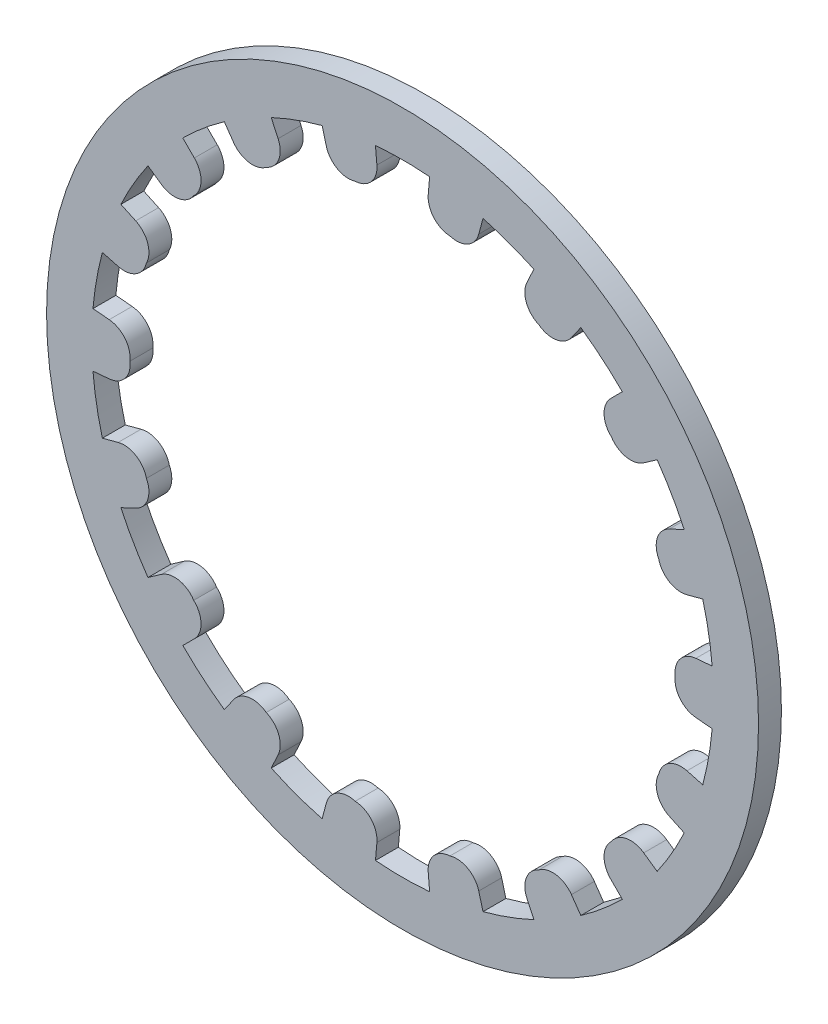
from build123d import *

# Parameters (mm, degrees)
BOSS_EXTRUDE1_DEPTH      = 0.254
BOSS_EXTRUDE1_DEPTH_BACK = 0.254
SKETCH1_R                = 7.8994


with BuildPart() as part:
    # Sketch1 → Boss-Extrude1 (new, two sides: drawn at the far end of the back side and taken through both)
    with BuildSketch(Plane.XY.offset(-BOSS_EXTRUDE1_DEPTH_BACK)):
        Circle(SKETCH1_R)
        with BuildLine():
            Line((-6.869858258, 0.601034718), (-6.508618542, 0.569430338))
            ThreePointArc((-6.508618542, 0.569430338), (-6.15764295, 0.382488604), (-6.048860848, 0))
            ThreePointArc((-6.048860848, 0), (-6.15764295, -0.382488604), (-6.508618542, -0.569430338))
            Line((-6.508618542, -0.569430338), (-6.869858258, -0.601034718))
            ThreePointArc((-6.869858258, -0.601034718), (-6.791332746, -1.197495198), (-6.661121091, -1.784842017))
            Line((-6.661121091, -1.784842017), (-6.310857462, -1.69098916))
            ThreePointArc((-6.310857462, -1.69098916), (-5.917110449, -1.746616205), (-5.684069903, -2.068832254))
            ThreePointArc((-5.684069903, -2.068832254), (-5.655472834, -2.465459643), (-5.92134417, -2.761168133))
            Line((-5.92134417, -2.761168133), (-6.24998913, -2.914417795))
            ThreePointArc((-6.24998913, -2.914417795), (-5.972197787, -3.44805), (-5.648954413, -3.955440463))
            Line((-5.648954413, -3.955440463), (-5.351913832, -3.747450409))
            ThreePointArc((-5.351913832, -3.747450409), (-4.9628871, -3.665053323), (-4.63369624, -3.888132806))
            ThreePointArc((-4.63369624, -3.888132806), (-4.471169229, -4.251059863), (-4.619868301, -4.619868301))
            Line((-4.619868301, -4.619868301), (-4.876279074, -4.876279074))
            ThreePointArc((-4.876279074, -4.876279074), (-4.432727635, -5.282719084), (-3.955440463, -5.648954413))
            Line((-3.955440463, -5.648954413), (-3.747450409, -5.351913832))
            ThreePointArc((-3.747450409, -5.351913832), (-3.410066323, -5.14143092), (-3.024430424, -5.238467158))
            ThreePointArc((-3.024430424, -5.238467158), (-2.747576627, -5.523919524), (-2.761168133, -5.92134417))
            Line((-2.761168133, -5.92134417), (-2.914417795, -6.24998913))
            ThreePointArc((-2.914417795, -6.24998913), (-2.35860511, -6.480214282), (-1.784842017, -6.661121091))
            Line((-1.784842017, -6.661121091), (-1.69098916, -6.310857462))
            ThreePointArc((-1.69098916, -6.310857462), (-1.44594122, -5.997676068), (-1.050373663, -5.95696506))
            ThreePointArc((-1.050373663, -5.95696506), (-0.692585734, -6.130512966), (-0.569430338, -6.508618542))
            Line((-0.569430338, -6.508618542), (-0.601034718, -6.869858258))
            ThreePointArc((-0.601034718, -6.869858258), (0, -6.8961), (0.601034718, -6.869858258))
            Line((0.601034718, -6.869858258), (0.569430338, -6.508618542))
            ThreePointArc((0.569430338, -6.508618542), (0.692585734, -6.130512966), (1.050373663, -5.95696506))
            ThreePointArc((1.050373663, -5.95696506), (1.44594122, -5.997676068), (1.69098916, -6.310857462))
            Line((1.69098916, -6.310857462), (1.784842017, -6.661121091))
            ThreePointArc((1.784842017, -6.661121091), (2.35860511, -6.480214282), (2.914417795, -6.24998913))
            Line((2.914417795, -6.24998913), (2.761168133, -5.92134417))
            ThreePointArc((2.761168133, -5.92134417), (2.747576627, -5.523919524), (3.024430424, -5.238467158))
            ThreePointArc((3.024430424, -5.238467158), (3.410066323, -5.14143092), (3.747450409, -5.351913832))
            Line((3.747450409, -5.351913832), (3.955440463, -5.648954413))
            ThreePointArc((3.955440463, -5.648954413), (4.432727635, -5.282719084), (4.876279074, -4.876279074))
            Line((4.876279074, -4.876279074), (4.619868301, -4.619868301))
            ThreePointArc((4.619868301, -4.619868301), (4.471169229, -4.251059863), (4.63369624, -3.888132806))
            ThreePointArc((4.63369624, -3.888132806), (4.9628871, -3.665053323), (5.351913832, -3.747450409))
            Line((5.351913832, -3.747450409), (5.648954413, -3.955440463))
            ThreePointArc((5.648954413, -3.955440463), (5.972197787, -3.44805), (6.24998913, -2.914417795))
            Line((6.24998913, -2.914417795), (5.92134417, -2.761168133))
            ThreePointArc((5.92134417, -2.761168133), (5.655472834, -2.465459643), (5.684069903, -2.068832254))
            ThreePointArc((5.684069903, -2.068832254), (5.917110449, -1.746616205), (6.310857462, -1.69098916))
            Line((6.310857462, -1.69098916), (6.661121091, -1.784842017))
            ThreePointArc((6.661121091, -1.784842017), (6.791332746, -1.197495198), (6.869858258, -0.601034718))
            Line((6.869858258, -0.601034718), (6.508618542, -0.569430338))
            ThreePointArc((6.508618542, -0.569430338), (6.15764295, -0.382488604), (6.048860848, 0))
            ThreePointArc((6.048860848, 0), (6.15764295, 0.382488604), (6.508618542, 0.569430338))
            Line((6.508618542, 0.569430338), (6.869858258, 0.601034718))
            ThreePointArc((6.869858258, 0.601034718), (6.791332746, 1.197495198), (6.661121091, 1.784842017))
            Line((6.661121091, 1.784842017), (6.310857462, 1.69098916))
            ThreePointArc((6.310857462, 1.69098916), (5.917110449, 1.746616205), (5.684069903, 2.068832254))
            ThreePointArc((5.684069903, 2.068832254), (5.655472834, 2.465459643), (5.92134417, 2.761168133))
            Line((5.92134417, 2.761168133), (6.24998913, 2.914417795))
            ThreePointArc((6.24998913, 2.914417795), (5.972197787, 3.44805), (5.648954413, 3.955440463))
            Line((5.648954413, 3.955440463), (5.351913832, 3.747450409))
            ThreePointArc((5.351913832, 3.747450409), (4.9628871, 3.665053323), (4.63369624, 3.888132806))
            ThreePointArc((4.63369624, 3.888132806), (4.471169229, 4.251059863), (4.619868301, 4.619868301))
            Line((4.619868301, 4.619868301), (4.876279074, 4.876279074))
            ThreePointArc((4.876279074, 4.876279074), (4.432727635, 5.282719084), (3.955440463, 5.648954413))
            Line((3.955440463, 5.648954413), (3.747450409, 5.351913832))
            ThreePointArc((3.747450409, 5.351913832), (3.410066323, 5.14143092), (3.024430424, 5.238467158))
            ThreePointArc((3.024430424, 5.238467158), (2.747576627, 5.523919524), (2.761168133, 5.92134417))
            Line((2.761168133, 5.92134417), (2.914417795, 6.24998913))
            ThreePointArc((2.914417795, 6.24998913), (2.35860511, 6.480214282), (1.784842017, 6.661121091))
            Line((1.784842017, 6.661121091), (1.69098916, 6.310857462))
            ThreePointArc((1.69098916, 6.310857462), (1.44594122, 5.997676068), (1.050373663, 5.95696506))
            ThreePointArc((1.050373663, 5.95696506), (0.692585734, 6.130512966), (0.569430338, 6.508618542))
            Line((0.569430338, 6.508618542), (0.601034718, 6.869858258))
            ThreePointArc((0.601034718, 6.869858258), (0, 6.8961), (-0.601034718, 6.869858258))
            Line((-0.601034718, 6.869858258), (-0.569430338, 6.508618542))
            ThreePointArc((-0.569430338, 6.508618542), (-0.692585734, 6.130512966), (-1.050373663, 5.95696506))
            ThreePointArc((-1.050373663, 5.95696506), (-1.44594122, 5.997676068), (-1.69098916, 6.310857462))
            Line((-1.69098916, 6.310857462), (-1.784842017, 6.661121091))
            ThreePointArc((-1.784842017, 6.661121091), (-2.35860511, 6.480214282), (-2.914417795, 6.24998913))
            Line((-2.914417795, 6.24998913), (-2.761168133, 5.92134417))
            ThreePointArc((-2.761168133, 5.92134417), (-2.747576627, 5.523919524), (-3.024430424, 5.238467158))
            ThreePointArc((-3.024430424, 5.238467158), (-3.410066323, 5.14143092), (-3.747450409, 5.351913832))
            Line((-3.747450409, 5.351913832), (-3.955440463, 5.648954413))
            ThreePointArc((-3.955440463, 5.648954413), (-4.432727635, 5.282719084), (-4.876279074, 4.876279074))
            Line((-4.876279074, 4.876279074), (-4.619868301, 4.619868301))
            ThreePointArc((-4.619868301, 4.619868301), (-4.471169229, 4.251059863), (-4.63369624, 3.888132806))
            ThreePointArc((-4.63369624, 3.888132806), (-4.9628871, 3.665053323), (-5.351913832, 3.747450409))
            Line((-5.351913832, 3.747450409), (-5.648954413, 3.955440463))
            ThreePointArc((-5.648954413, 3.955440463), (-5.972197787, 3.44805), (-6.24998913, 2.914417795))
            Line((-6.24998913, 2.914417795), (-5.92134417, 2.761168133))
            ThreePointArc((-5.92134417, 2.761168133), (-5.655472834, 2.465459643), (-5.684069903, 2.068832254))
            ThreePointArc((-5.684069903, 2.068832254), (-5.917110449, 1.746616205), (-6.310857462, 1.69098916))
            Line((-6.310857462, 1.69098916), (-6.661121091, 1.784842017))
            ThreePointArc((-6.661121091, 1.784842017), (-6.791332746, 1.197495198), (-6.869858258, 0.601034718))
        make_face(mode=Mode.SUBTRACT)
    extrude(amount=BOSS_EXTRUDE1_DEPTH + BOSS_EXTRUDE1_DEPTH_BACK)


solid = part.part
